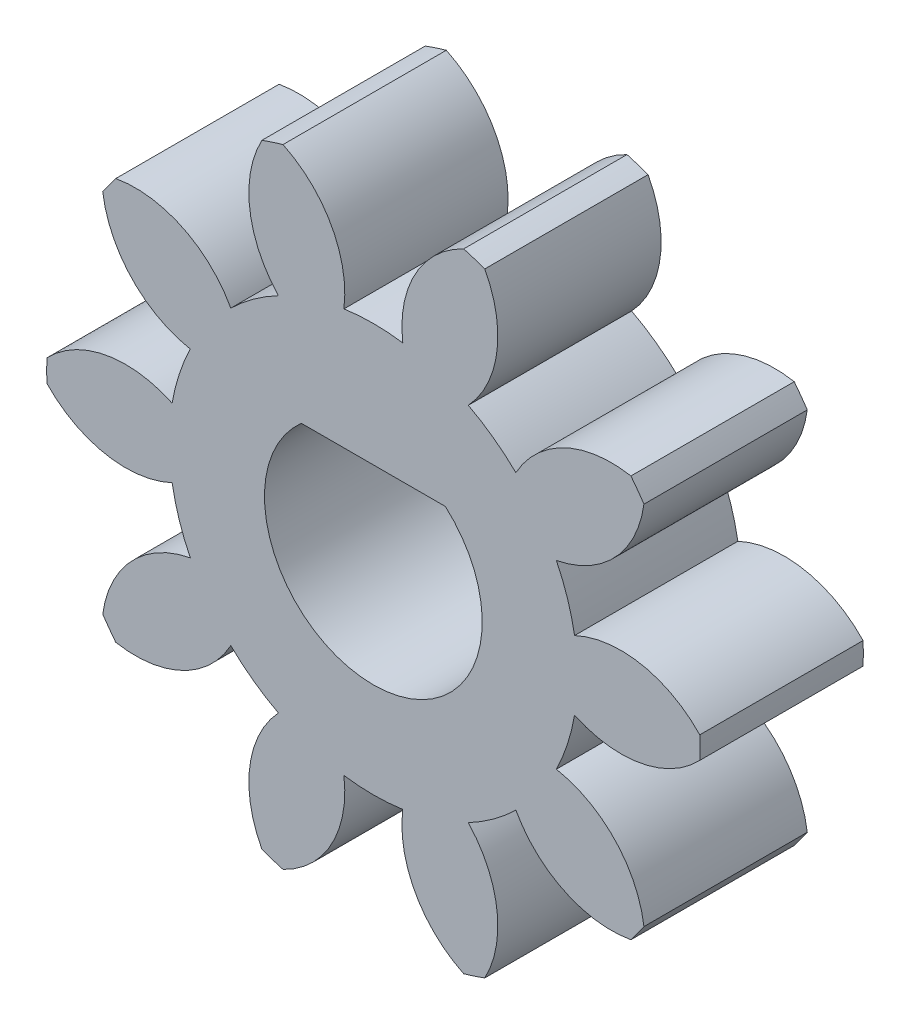
from build123d import *

# Parameters (mm, degrees)
SKETCH1_R           = 6
BOSS_EXTRUDE1_DEPTH = 3
CUT_EXTRUDE1_DEPTH  = 4
CIRPATTERN1_COUNT   = 10
CUT_EXTRUDE3_DEPTH  = 4


with BuildPart() as part:
    # Sketch1 → Boss-Extrude1 (new body)
    with BuildSketch(Plane.XY):
        Circle(SKETCH1_R)
    extrude(amount=BOSS_EXTRUDE1_DEPTH)

    # Sketch2 → Cut-Extrude1 (cut, through all)
    with BuildSketch(Plane.XY.offset(3)):
        with BuildLine():
            ThreePointArc((-1.659502931, 5.765938781), (-0.768019042, 4.919153149), (-0.540379921, 3.710861024))
            ThreePointArc((-0.540379921, 3.710861024), (0, 3.75), (0.540379921, 3.710861024))
            ThreePointArc((0.540379921, 3.710861024), (0.768019042, 4.919153149), (1.659502931, 5.765938781))
            ThreePointArc((1.659502931, 5.765938781), (0, 6), (-1.659502931, 5.765938781))
        make_face()
    cut_extrude1 = extrude(amount=-CUT_EXTRUDE1_DEPTH, mode=Mode.SUBTRACT)

    # CirPattern1: Cut-Extrude1 ×10 about axis
    cirpattern1_axis = Axis((0, 0, 0), (0, 0, 1))
    for i in range(1, CIRPATTERN1_COUNT):
        add(cut_extrude1.rotate(cirpattern1_axis, i * 360 / CIRPATTERN1_COUNT), mode=Mode.SUBTRACT)

    # Sketch5 → Cut-Extrude3 (cut, through all)
    with BuildSketch(Plane.XY.offset(3)):
        with BuildLine():
            Line((1.322875656, 1.5), (-1.322875656, 1.5))
            ThreePointArc((-1.322875656, 1.5), (0, -2), (1.322875656, 1.5))
        make_face()
    extrude(amount=-CUT_EXTRUDE3_DEPTH, mode=Mode.SUBTRACT)


solid = part.part
